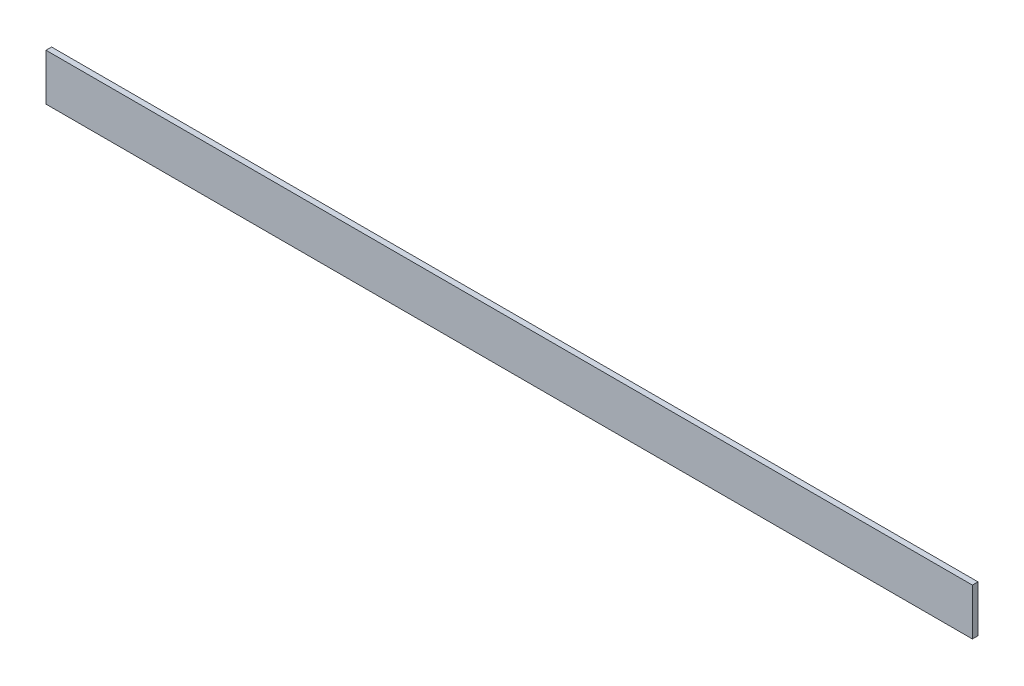
from build123d import *

# Parameters (mm, degrees)
EXTRUDE_1_DEPTH     = 496
SKETCH_2_W          = 25
SKETCH_2_H          = 22
CUT_EXTRUDE_1_DEPTH = 26


with BuildPart() as part:
    # Эскиз1 → Вытянуть-Тонкостенный1 (new body)
    with BuildSketch(Plane(origin=(0, 0, 0), x_dir=(0, 0, -1), z_dir=(1, 0, 0))):
        Polygon((0, 25), (0, 0), (25, 0), (25, 3), (3, 3), (3, 25), align=None)
    extrude(amount=EXTRUDE_1_DEPTH)

    # Эскиз2 → Вырез-Вытянуть1 (cut, through all)
    with BuildSketch(Plane.XZ):
        with Locations((483.5, -14)):
            Rectangle(SKETCH_2_W, SKETCH_2_H)
        with Locations((12.5, -14)):
            Rectangle(SKETCH_2_W, SKETCH_2_H)
    extrude(amount=-CUT_EXTRUDE_1_DEPTH, mode=Mode.SUBTRACT)


solid = part.part
